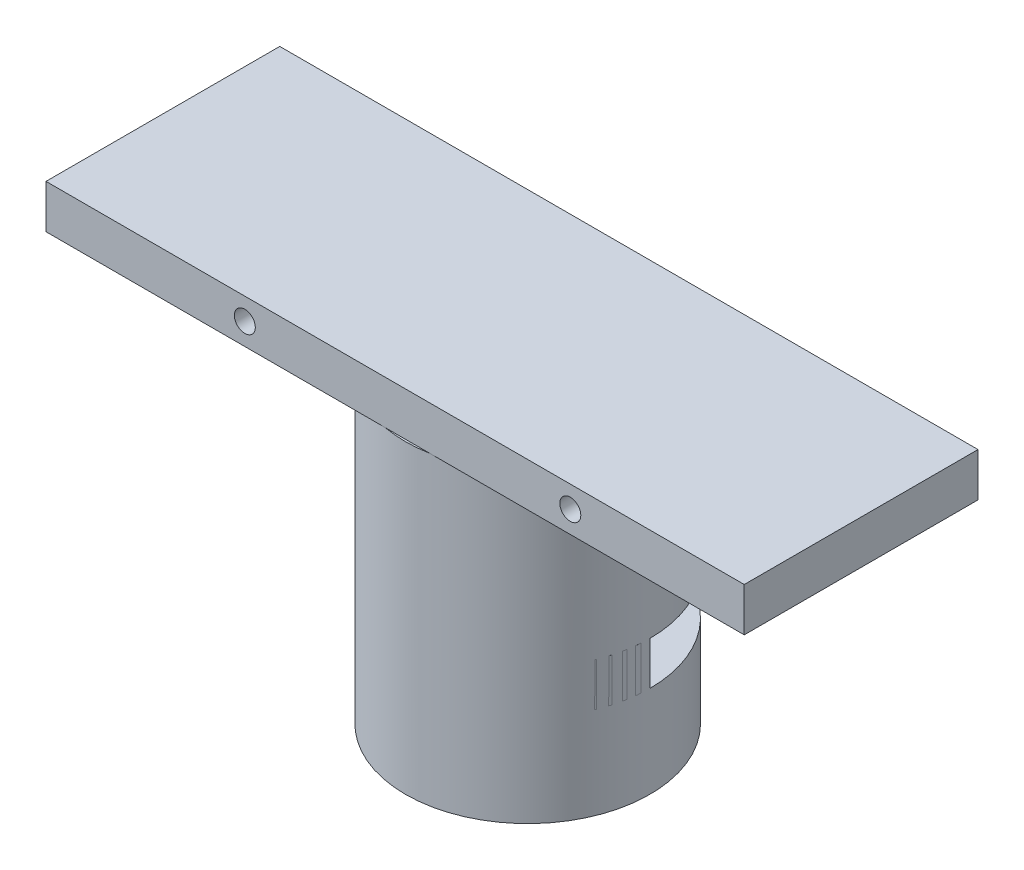
from build123d import *

# Parameters (mm, degrees)
SKETCH1_R                    = 8.89
BOSS_EXTRUDE2_DEPTH          = 19.05
SHELL7_T                     = -2.54
SKETCH3_R                    = 8.89
BOSS_EXTRUDE4_DEPTH          = 3.175
SKETCH4_W                    = 50.8
SKETCH4_H                    = 17.006105847
BOSS_EXTRUDE5_DEPTH          = 3.175
SKETCH5_W                    = 3.81
SKETCH5_H                    = 3.15
CUT_REVOLVE1_ANGLE           = 60
CUT_REVOLVE1_OTHER_WAY_ANGLE = 60
SKETCH6_R                    = 0.762
CUT_EXTRUDE1_DEPTH           = 39.937338239
CUT_EXTRUDE1_DEPTH_BACK      = 39.937338239
CUT_EXTRUDE2_DEPTH           = 36.565821813


with BuildPart() as part:
    # Sketch1 → Boss-Extrude2 (new body)
    with BuildSketch(Plane(origin=(0, 0, 0), x_dir=(1, 0, 0), z_dir=(0, 1, 0))):
        with Locations(Location((0, 0, 0), (0, 0, 90))):
            Circle(SKETCH1_R)
    extrude(amount=BOSS_EXTRUDE2_DEPTH)

    # Shell7
    shell7_openings = [part.faces().sort_by_distance(p)[0] for p in [
        (0, 0, 0),
    ]]
    offset(amount=SHELL7_T, openings=shell7_openings, kind=Kind.INTERSECTION)

    # Sketch3 → Boss-Extrude4 (add)
    with BuildSketch(Plane(origin=(0, 19.05, 0), x_dir=(1, 0, 0), z_dir=(0, 1, 0))):
        with Locations(Location((0, 0, 0), (0, 0, 90))):
            Circle(SKETCH3_R)
    extrude(amount=BOSS_EXTRUDE4_DEPTH)

    # Sketch4 → Boss-Extrude5 (add)
    with BuildSketch(Plane(origin=(0, 22.225, 0), x_dir=(1, 0, 0), z_dir=(0, 1, 0))):
        with Locations((-0.90484663, -0.237125368)):
            Rectangle(SKETCH4_W, SKETCH4_H)
    extrude(amount=BOSS_EXTRUDE5_DEPTH)

    # Sketch5 → Cut-Revolve1 (revolve, cut)
    with BuildSketch(Plane(origin=(0, 0, -0.018592303), x_dir=(-1, 0, 0), z_dir=(0, 0, -1))):
        with Locations((-6.985, 8.255)):
            Rectangle(SKETCH5_W, SKETCH5_H)
        with Locations((6.985, 8.255)):
            Rectangle(SKETCH5_W, SKETCH5_H)
    revolve(axis=Axis((0, 0, -0.018592303), (0, 1, 0)), revolution_arc=CUT_REVOLVE1_ANGLE, mode=Mode.SUBTRACT)

    # Sketch5 → Cut-Revolve1 other way (revolve, cut)
    with BuildSketch(Plane(origin=(0, 0, -0.018592303), x_dir=(-1, 0, 0), z_dir=(0, 0, -1))):
        with Locations((-6.985, 8.255)):
            Rectangle(SKETCH5_W, SKETCH5_H)
        with Locations((6.985, 8.255)):
            Rectangle(SKETCH5_W, SKETCH5_H)
    revolve(axis=Axis((0, 0, -0.018592303), (0, -1, 0)), revolution_arc=CUT_REVOLVE1_OTHER_WAY_ANGLE, mode=Mode.SUBTRACT)

    # Sketch6 → Cut-Extrude1 (cut, two sides)
    with BuildSketch(Plane(origin=(0, 0, -4.489512434), x_dir=(-1, 0, 0), z_dir=(0, 0, -1))) as cut_extrude1_sk:
        with Locations((-11.839923773, 23.8125)):
            Circle(SKETCH6_R)
        with Locations((11.839923773, 23.8125)):
            Circle(SKETCH6_R)
    extrude(amount=CUT_EXTRUDE1_DEPTH, mode=Mode.SUBTRACT)
    extrude(cut_extrude1_sk.sketch, amount=-CUT_EXTRUDE1_DEPTH_BACK, mode=Mode.SUBTRACT)

    # Sketch7 → Cut-Extrude2 (cut, through all)
    with BuildSketch(Plane(origin=(0, 22.225, 0), x_dir=(1, 0, 0), z_dir=(0, 1, 0))):
        with BuildLine():
            Line((-3.272085213, 8.265927556), (3.272085213, 8.265927556))
            ThreePointArc((3.272085213, 8.265927556), (0, 8.89), (-3.272085213, 8.265927556))
        make_face()
    extrude(amount=-CUT_EXTRUDE2_DEPTH, mode=Mode.SUBTRACT)


solid = part.part
